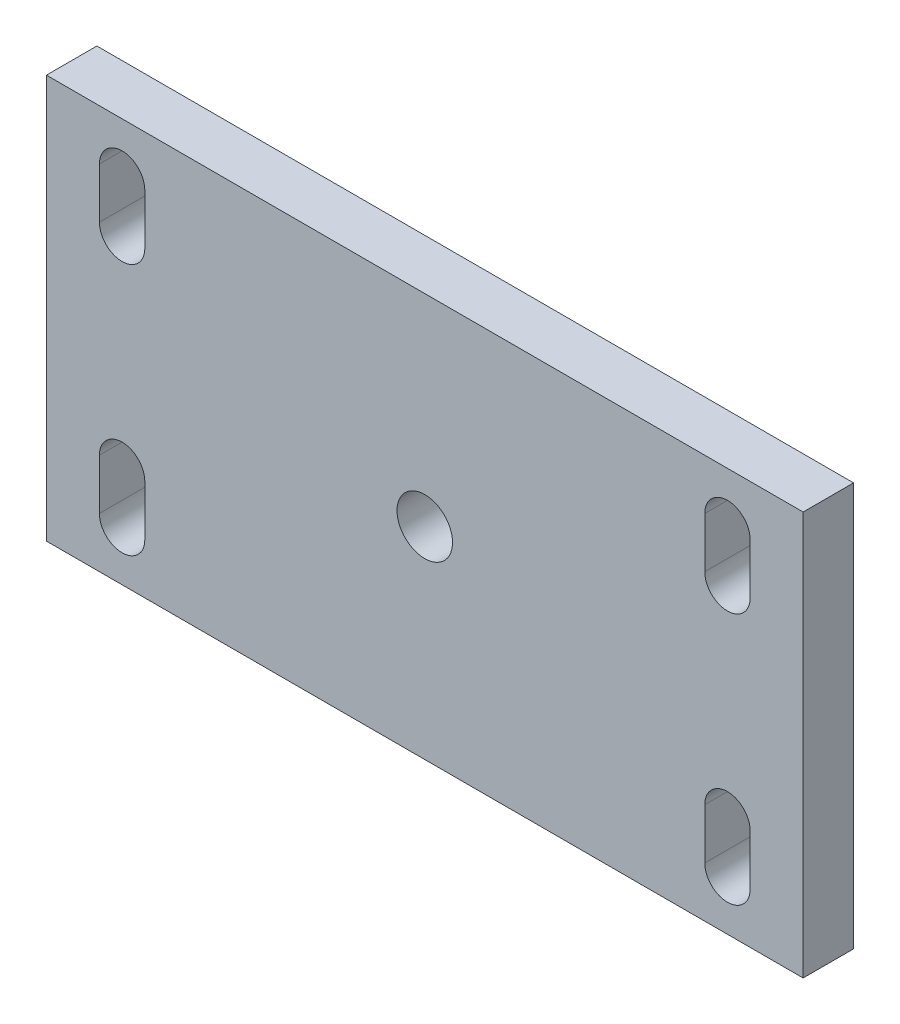
from build123d import *

# Parameters (mm, degrees)
SKETCH_1_W      = 150
SKETCH_1_H      = 80
EXTRUDE_1_DEPTH = 10
MM_1_D          = 11
MM_1_DEPTH      = 24.5
MM_1_TIP        = 3.304733405


with BuildPart() as part:
    # 草图1 → 凸台-拉伸1 (new body)
    with BuildSketch(Plane.XY):
        Rectangle(SKETCH_1_W, SKETCH_1_H)
        with BuildLine():
            Line((-55.5, -20), (-55.5, -30))
            ThreePointArc((-55.5, -30), (-60, -34.5), (-64.5, -30))
            Line((-64.5, -30), (-64.5, -20))
            ThreePointArc((-64.5, -20), (-60, -15.5), (-55.5, -20))
        make_face(mode=Mode.SUBTRACT)
        with BuildLine():
            Line((-55.5, 20), (-55.5, 30))
            ThreePointArc((-55.5, 30), (-60, 34.5), (-64.5, 30))
            Line((-64.5, 30), (-64.5, 20))
            ThreePointArc((-64.5, 20), (-60, 15.5), (-55.5, 20))
        make_face(mode=Mode.SUBTRACT)
        with BuildLine():
            Line((55.5, -20), (55.5, -30))
            ThreePointArc((55.5, -30), (60, -34.5), (64.5, -30))
            Line((64.5, -30), (64.5, -20))
            ThreePointArc((64.5, -20), (60, -15.5), (55.5, -20))
        make_face(mode=Mode.SUBTRACT)
        with BuildLine():
            Line((55.5, 20), (55.5, 30))
            ThreePointArc((55.5, 30), (60, 34.5), (64.5, 30))
            Line((64.5, 30), (64.5, 20))
            ThreePointArc((64.5, 20), (60, 15.5), (55.5, 20))
        make_face(mode=Mode.SUBTRACT)
    extrude(amount=EXTRUDE_1_DEPTH)

    # 大小mm 暗销孔1
    with Locations(Plane(origin=(0, 0, 0), x_dir=(-1, 0, 0), z_dir=(0, 0, -1))):
        with Locations((0, 0)):
            Hole(MM_1_D / 2, depth=MM_1_DEPTH)
            with Locations((0, 0, -(MM_1_DEPTH + MM_1_TIP / 2))):  # 118° drill point
                Cone(0, MM_1_D / 2, MM_1_TIP, mode=Mode.SUBTRACT)


solid = part.part
